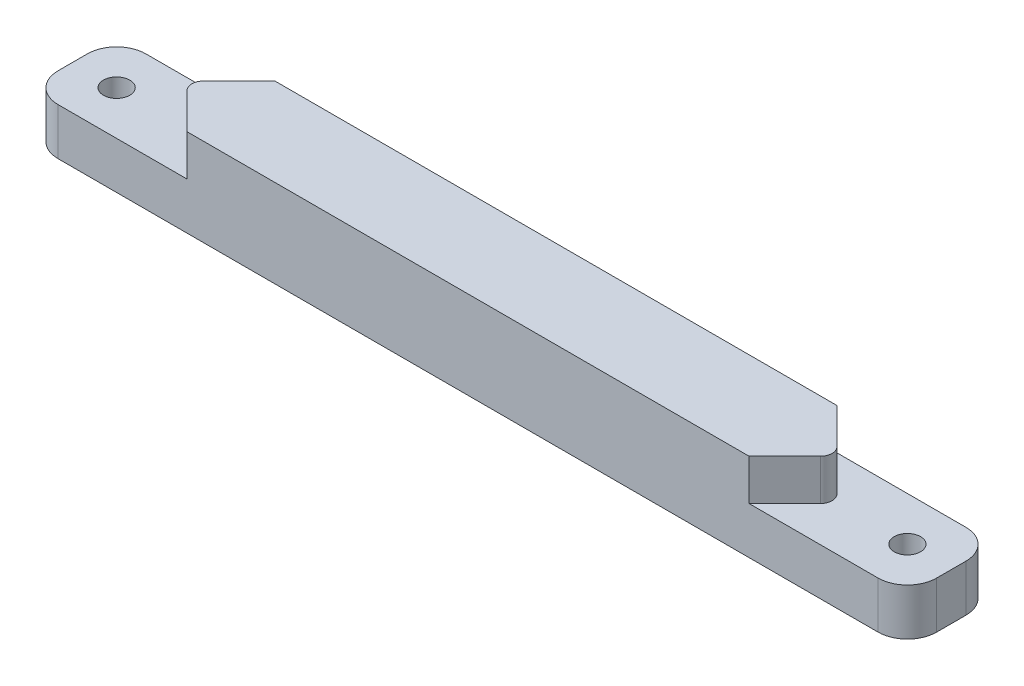
from build123d import *

# Parameters (mm, degrees)
SKETCH1_W            = 150
SKETCH1_H            = 15
BOSS_EXTRUDE1_DEPTH  = 15
SKETCH2_W            = 16
SKETCH2_H            = 15
CUT_EXTRUDE1_DEPTH   = 7
SKETCH3_R            = 2.25
CUT_EXTRUDE2_DEPTH   = 8
FILLET1_R            = 5
CUT_EXTRUDE3_DEPTH   = 7
FILLET2_R            = 2
FILLET2_OF_MIRROR2_R = 2


with BuildPart() as part:
    # Sketch1 → Boss-Extrude1 (new body)
    with BuildSketch(Plane(origin=(0, 0, 0), x_dir=(1, 0, 0), z_dir=(0, 1, 0))):
        with Locations((75, 7.5)):
            Rectangle(SKETCH1_W, SKETCH1_H)
    extrude(amount=BOSS_EXTRUDE1_DEPTH)

    # Sketch2 → Cut-Extrude1 (cut)
    with BuildSketch(Plane(origin=(0, 15, 0), x_dir=(1, 0, 0), z_dir=(0, 1, 0))):
        with Locations((8, 7.5)):
            Rectangle(SKETCH2_W, SKETCH2_H)
    cut_extrude1 = extrude(amount=-CUT_EXTRUDE1_DEPTH, mode=Mode.SUBTRACT)

    # Sketch3 → Cut-Extrude2 (cut)
    with BuildSketch(Plane(origin=(0, 8, 0), x_dir=(1, 0, 0), z_dir=(0, 1, 0))):
        with Locations((7.5, 7.5)):
            Circle(SKETCH3_R)
    cut_extrude2 = extrude(amount=-CUT_EXTRUDE2_DEPTH, mode=Mode.SUBTRACT)

    # Mirror1: Cut-Extrude1, Cut-Extrude2 across plane
    add(cut_extrude1.mirror(Plane(origin=(75, 0, 0), x_dir=(0, 0, 1), z_dir=(1, 0, 0))), mode=Mode.SUBTRACT)
    add(cut_extrude2.mirror(Plane(origin=(75, 0, 0), x_dir=(0, 0, 1), z_dir=(1, 0, 0))), mode=Mode.SUBTRACT)

    # Fillet1
    fillet1_edges = [part.edges().sort_by_distance(p)[0] for p in [
        (0, 4, -15),
        (0, 4, 0),
        (150, 4, -15),
        (150, 4, 0),
    ]]
    fillet(fillet1_edges, radius=FILLET1_R)

    # Sketch4 → Cut-Extrude3 (cut)
    with BuildSketch(Plane(origin=(0, 15, 0), x_dir=(1, 0, 0), z_dir=(0, 1, 0))):
        Polygon((19.52081528, 7.5), (16, 11.02081528), (16, 0), (27.02081528, 0), align=None)
        Polygon((16, 15), (16, 11.02081528), (19.52081528, 7.5), (27.02081528, 15), align=None)
    cut_extrude3 = extrude(amount=-CUT_EXTRUDE3_DEPTH, mode=Mode.SUBTRACT)

    # Fillet2
    fillet2_edges = [part.edges().sort_by_distance(p)[0] for p in [
        (19.52081528, 11.5, -7.5),
    ]]
    fillet(fillet2_edges, radius=FILLET2_R)

    # Mirror2: Cut-Extrude3 across plane
    add(cut_extrude3.mirror(Plane(origin=(75, 0, 0), x_dir=(0, 0, 1), z_dir=(1, 0, 0))), mode=Mode.SUBTRACT)

    # Fillet2 of Mirror2
    fillet2_of_mirror2_edges = [part.edges().sort_by_distance(p)[0] for p in [
        (130.47918472, 11.5, -7.5),
    ]]
    fillet(fillet2_of_mirror2_edges, radius=FILLET2_OF_MIRROR2_R)


solid = part.part
